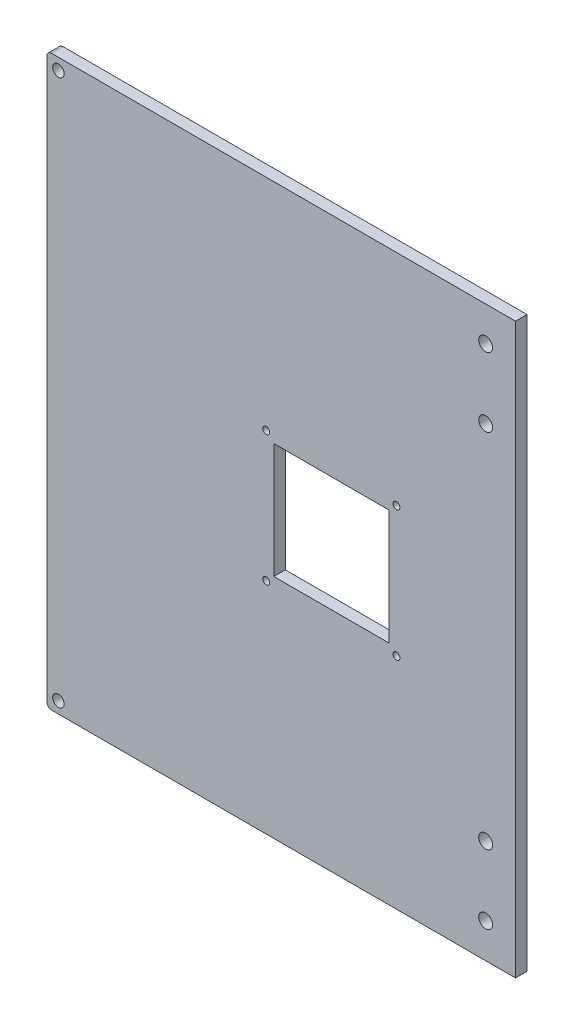
from build123d import *

# Parameters (mm, degrees)
SKETCH1_R           = 2.5
BOSS_EXTRUDE1_DEPTH = 5
SKETCH2_R           = 1.5
SKETCH2_W           = 50
SKETCH2_H           = 50
CUT_EXTRUDE1_DEPTH  = 5
SKETCH3_W           = 80
SKETCH3_H           = 300
CUT_EXTRUDE2_DEPTH  = 10
SKETCH5_R           = 3
CUT_EXTRUDE4_DEPTH  = 10
SKETCH4_R           = 3
CUT_EXTRUDE3_DEPTH  = 10


with BuildPart() as part:
    # Sketch1 → Boss-Extrude1 (new body)
    with BuildSketch(Plane.XY):
        with BuildLine():
            Line((-123.5, 121.5), (-123.5, -121.5))
            ThreePointArc((-123.5, -121.5), (-122.914213562, -122.914213562), (-121.5, -123.5))
            Line((-121.5, -123.5), (121.5, -123.5))
            ThreePointArc((121.5, -123.5), (122.914213562, -122.914213562), (123.5, -121.5))
            Line((123.5, -121.5), (123.5, 121.5))
            ThreePointArc((123.5, 121.5), (122.914213562, 122.914213562), (121.5, 123.5))
            Line((121.5, 123.5), (-121.5, 123.5))
            ThreePointArc((-121.5, 123.5), (-122.914213562, 122.914213562), (-123.5, 121.5))
        make_face()
        with Locations((-118.5, 118.5)):
            Circle(SKETCH1_R, mode=Mode.SUBTRACT)
        with Locations((118.5, 118.5)):
            Circle(SKETCH1_R, mode=Mode.SUBTRACT)
        with Locations((118.5, -118.5)):
            Circle(SKETCH1_R, mode=Mode.SUBTRACT)
        with Locations((-118.5, -118.5)):
            Circle(SKETCH1_R, mode=Mode.SUBTRACT)
    extrude(amount=BOSS_EXTRUDE1_DEPTH)

    # Sketch2 → Cut-Extrude1 (cut)
    with BuildSketch(Plane(origin=(0, 0, 0), x_dir=(-1, 0, 0), z_dir=(0, 0, -1))):
        with Locations((28.284271247, 28.284271247)):
            Circle(SKETCH2_R)
        with Locations((28.284271247, -28.284271247)):
            Circle(SKETCH2_R)
        with Locations((-28.284271247, -28.284271247)):
            Circle(SKETCH2_R)
        with Locations((-28.284271247, 28.284271247)):
            Circle(SKETCH2_R)
        Rectangle(SKETCH2_W, SKETCH2_H)
    extrude(amount=-CUT_EXTRUDE1_DEPTH, mode=Mode.SUBTRACT)

    # Sketch3 → Cut-Extrude2 (cut)
    with BuildSketch(Plane(origin=(0, 0, 0), x_dir=(-1, 0, 0), z_dir=(0, 0, -1))):
        with Locations((-120, 0)):
            Rectangle(SKETCH3_W, SKETCH3_H)
    extrude(amount=-CUT_EXTRUDE2_DEPTH, mode=Mode.SUBTRACT)

    # Sketch5 → Cut-Extrude4 (cut)
    with BuildSketch(Plane(origin=(0, 0, 0), x_dir=(-1, 0, 0), z_dir=(0, 0, -1))):
        with Locations((-67, 108.5)):
            Circle(SKETCH5_R)
        with Locations((-67, 78.5)):
            Circle(SKETCH5_R)
        with Locations((-67, -108.5)):
            Circle(SKETCH5_R)
        with Locations((-67, -78.5)):
            Circle(SKETCH5_R)
    extrude(amount=-CUT_EXTRUDE4_DEPTH, mode=Mode.SUBTRACT)

    # Sketch4 → Cut-Extrude3 (cut)
    with BuildSketch(Plane(origin=(0, 0, 0), x_dir=(-1, 0, 0), z_dir=(0, 0, -1))):
        with Locations((-93, 78.5)):
            Circle(SKETCH4_R)
        with Locations((-93, 108.5)):
            Circle(SKETCH4_R)
        with Locations((-93, -78.5)):
            Circle(SKETCH4_R)
        with Locations((-93, -108.5)):
            Circle(SKETCH4_R)
    extrude(amount=-CUT_EXTRUDE3_DEPTH, mode=Mode.SUBTRACT)


solid = part.part
